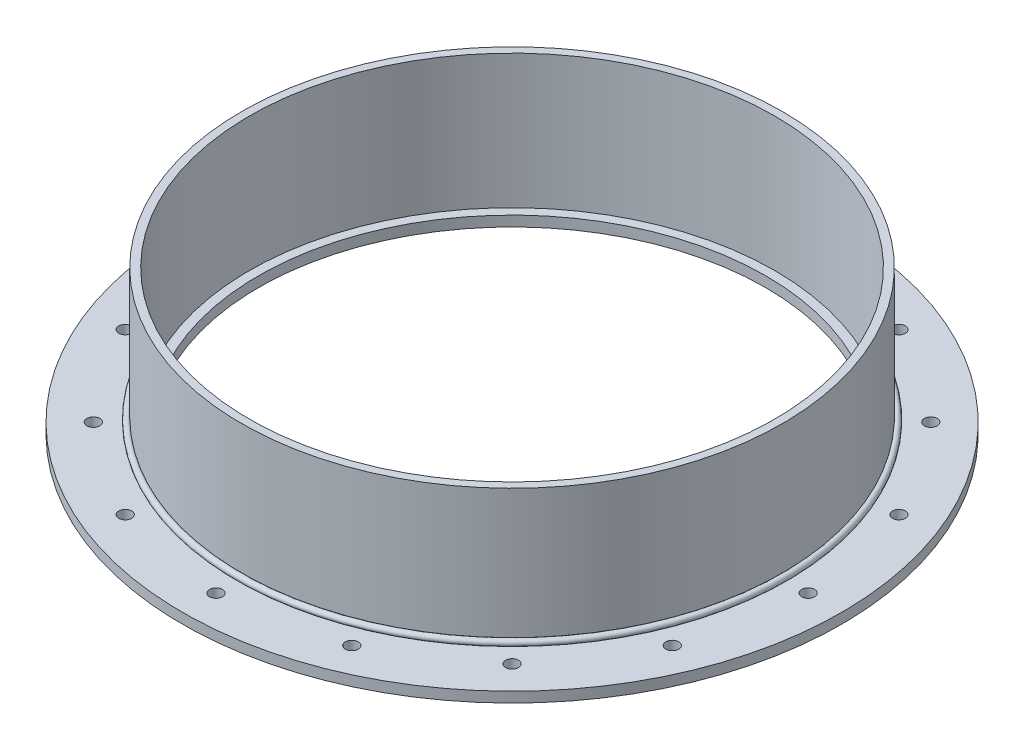
from build123d import *

# Parameters (mm, degrees)
SKETCH1_W          = 46.83125
SKETCH1_H          = 6.35
SKETCH2_W          = 4.7625
SKETCH2_H          = 82.55
SKETCH4_R          = 3.96875
CUT_EXTRUDE1_DEPTH = 7.35
CIRPATTERN1_COUNT  = 16


with BuildPart() as part:
    # Sketch1 → Revolve1 (revolve)
    with BuildSketch(Plane.XY, mode=Mode.PRIVATE) as revolve1_sk:
        with Locations((-179.784375, 3.175)):
            Rectangle(SKETCH1_W, SKETCH1_H)
    revolve(revolve1_sk.sketch.rotate(Axis((0, 0, 0), (0, 1, 0)), 270), axis=Axis((0, 0, 0), (0, 1, 0)))  # turned: the seam where the file's is

    # Sketch4 → Cut-Extrude1 (cut, through all)
    with BuildSketch(Plane(origin=(0, 6.35, 0), x_dir=(1, 0, 0), z_dir=(0, 1, 0))):
        with Locations(Location((0, 182.5625, 0), (0, 0, 270))):  # turned: the seam where the file's is
            Circle(SKETCH4_R)
    cut_extrude1 = extrude(amount=-CUT_EXTRUDE1_DEPTH, mode=Mode.SUBTRACT)

    # CirPattern1: Cut-Extrude1 ×16 about axis
    cirpattern1_axis = Axis((0, 0, 0), (0, 1, 0))
    for i in range(1, CIRPATTERN1_COUNT):
        add(cut_extrude1.rotate(cirpattern1_axis, i * 360 / CIRPATTERN1_COUNT), mode=Mode.SUBTRACT)


with BuildPart() as body_2:
    # Sketch2 → Revolve2 (revolve)
    with BuildSketch(Plane.XY, mode=Mode.PRIVATE) as revolve2_sk:
        with Locations((-164.30625, 47.625)):
            Rectangle(SKETCH2_W, SKETCH2_H)
    revolve(revolve2_sk.sketch.rotate(Axis((0, 0, 0), (0, 1, 0)), 270), axis=Axis((0, 0, 0), (0, 1, 0)))  # turned: the seam where the file's is


with BuildPart() as body_3:
    # Sketch3 → Revolve3 (revolve)
    with BuildSketch(Plane.XY, mode=Mode.PRIVATE) as revolve3_sk:
        with BuildLine():
            Line((-166.6875, 6.35), (-169.473275819, 6.35))
            ThreePointArc((-169.473275819, 6.35), (-169.314037909, 8.976537909), (-166.6875, 9.135775819))
            Line((-166.6875, 9.135775819), (-166.6875, 6.35))
        make_face()
    revolve(revolve3_sk.sketch.rotate(Axis((0, 0, 0), (0, 1, 0)), 270), axis=Axis((0, 0, 0), (0, 1, 0)))  # turned: the seam where the file's is


solid = Compound([part.part, body_2.part, body_3.part])
